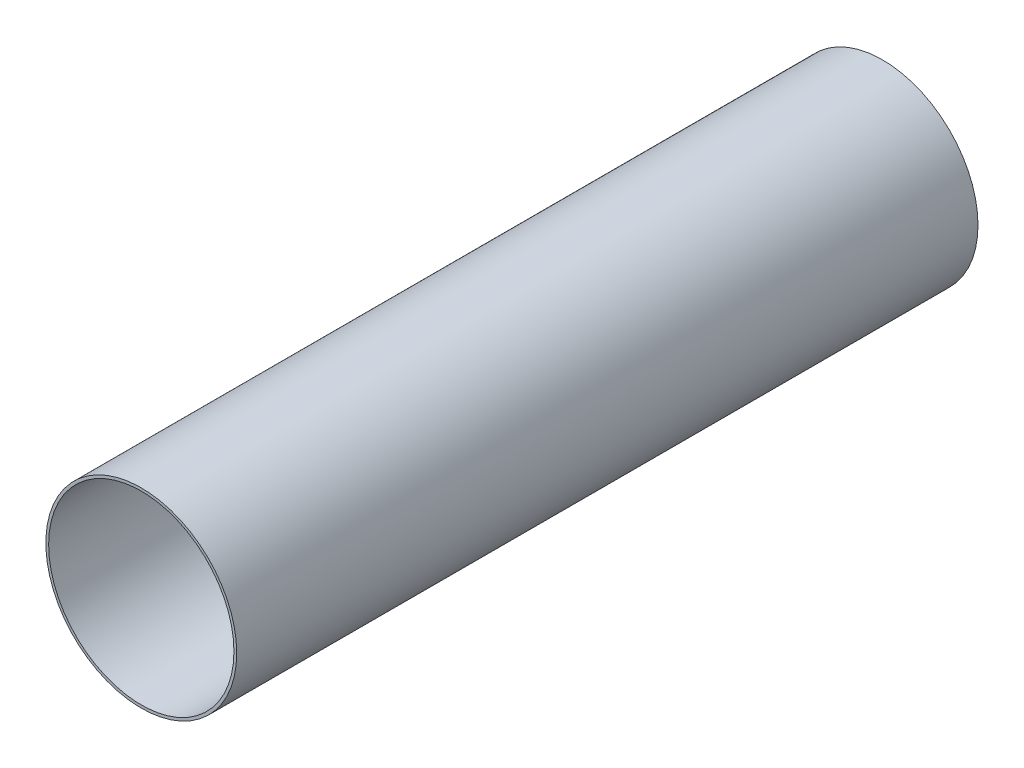
from build123d import *

# Parameters (mm, degrees)
SKETCH1_R           = 65.405
SKETCH1_R_2         = 63.5
BOSS_EXTRUDE1_DEPTH = 254


with BuildPart() as part:
    # Sketch1 → Boss-Extrude1 (new body, symmetric)
    with BuildSketch(Plane.XY):
        Circle(SKETCH1_R)
        Circle(SKETCH1_R_2, mode=Mode.SUBTRACT)
    extrude(amount=BOSS_EXTRUDE1_DEPTH, both=True)


solid = part.part
